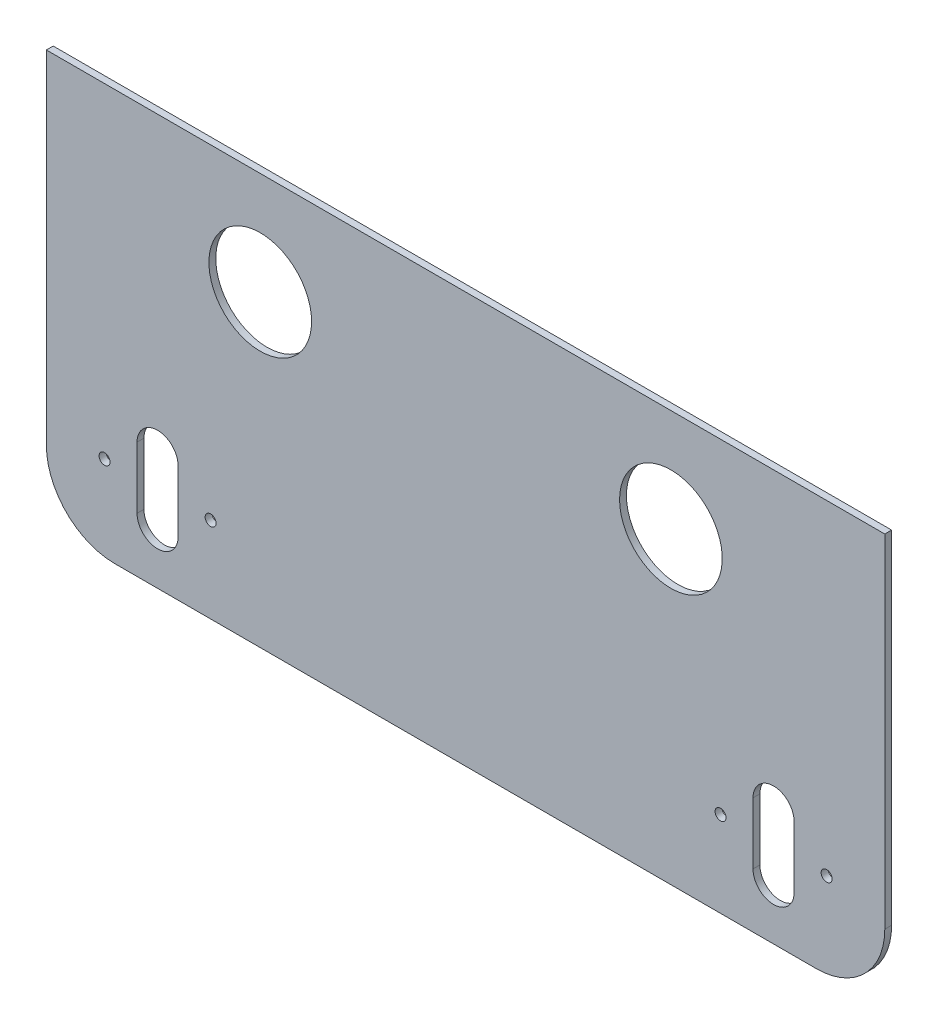
from build123d import *

# Parameters (mm, degrees)
SKETCH_1_W          = 245
SKETCH_1_H          = 120
SKETCH_1_R          = 15
EXTRUDE_1_DEPTH     = 2
FILLET_1_R          = 20
FILLET_2_R          = 20
SKETCH_3_R          = 1.6
CUT_EXTRUDE_1_DEPTH = 10


with BuildPart() as part:
    # 草图1 → 凸台-拉伸1 (new body)
    with BuildSketch(Plane.XY):
        with Locations((48.291102509, -15.293659776)):
            Rectangle(SKETCH_1_W, SKETCH_1_H)
        with Locations((-11.708897491, 14.706340224)):
            Circle(SKETCH_1_R, mode=Mode.SUBTRACT)
        with Locations((108.291102509, 14.706340224)):
            Circle(SKETCH_1_R, mode=Mode.SUBTRACT)
    extrude(amount=EXTRUDE_1_DEPTH)

    # 圆角1
    fillet_1_edges = [part.edges().sort_by_distance(p)[0] for p in [
        (170.791102509, -75.293659776, 1),
    ]]
    fillet(fillet_1_edges, radius=FILLET_1_R)

    # 圆角2
    fillet_2_edges = [part.edges().sort_by_distance(p)[0] for p in [
        (-74.208897491, -75.293659776, 1),
    ]]
    fillet(fillet_2_edges, radius=FILLET_2_R)

    # 草图3 → 切除-拉伸1 (cut)
    with BuildSketch(Plane.XY.offset(2)):
        with Locations((-26.208897491, -50.293659776)):
            Circle(SKETCH_3_R)
        with Locations((-57.208897491, -50.293659776)):
            Circle(SKETCH_3_R)
        with Locations((153.791102509, -50.293659776)):
            Circle(SKETCH_3_R)
        with Locations((122.791102509, -50.293659776)):
            Circle(SKETCH_3_R)
        with BuildLine():
            Line((-47.708897491, -59.293659776), (-47.708897491, -41.293659776))
            ThreePointArc((-47.708897491, -41.293659776), (-41.708897491, -35.293659776), (-35.708897491, -41.293659776))
            Line((-35.708897491, -41.293659776), (-35.708897491, -59.293659776))
            ThreePointArc((-35.708897491, -59.293659776), (-41.708897491, -65.293659776), (-47.708897491, -59.293659776))
        make_face()
        with BuildLine():
            Line((144.291102509, -59.293659776), (144.291102509, -41.293659776))
            ThreePointArc((144.291102509, -41.293659776), (138.291102509, -35.293659776), (132.291102509, -41.293659776))
            Line((132.291102509, -41.293659776), (132.291102509, -59.293659776))
            ThreePointArc((132.291102509, -59.293659776), (138.291102509, -65.293659776), (144.291102509, -59.293659776))
        make_face()
    extrude(amount=-CUT_EXTRUDE_1_DEPTH, mode=Mode.SUBTRACT)


solid = part.part
